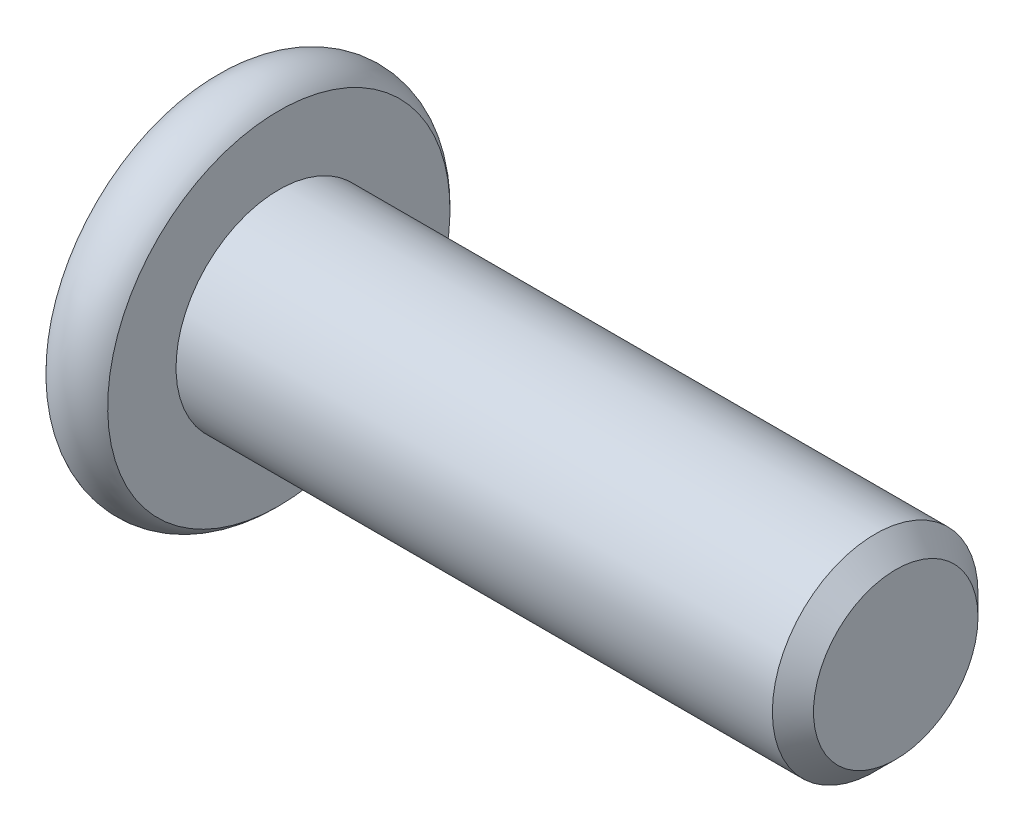
from build123d import *

# Parameters (mm, degrees)
SKETCH2_R           = 2.5
BOSS_EXTRUDE1_DEPTH = 15
CHAMFER1_SIZE       = 0.5
CUT_EXTRUDE1_DEPTH  = 2.3
SKETCH8_R           = 1.782050808
CUT_EXTRUDE2_DEPTH  = 1
CUT_EXTRUDE2_TAPER  = 45


with BuildPart() as part:
    # Sketch2 → Boss-Extrude1 (new body)
    with BuildSketch(Plane(origin=(0, 0, 0), x_dir=(0, 0, -1), z_dir=(1, 0, 0))):
        Circle(SKETCH2_R)
    extrude(amount=-BOSS_EXTRUDE1_DEPTH)

    # Chamfer1
    chamfer1_edges = [part.edges().sort_by_distance(p)[0] for p in [
        (0, 0, 2.5),
    ]]
    chamfer(chamfer1_edges, length=CHAMFER1_SIZE)

    # Sketch6 → Revolve1 (revolve)
    with BuildSketch(Plane.XY):
        with BuildLine():
            Line((-16.5, 0), (-16.5, 4.161437828))
            ThreePointArc((-16.5, 4.161437828), (-15.75, 4.5), (-15, 4.161437828))
            Line((-15, 4.161437828), (-15, 0))
            Line((-15, 0), (-16.5, 0))
        make_face()
    revolve(axis=Axis((-15, 0, 0), (1, 0, 0)))

    # Sketch7 → Cut-Extrude1 (cut)
    with BuildSketch(Plane.ZY.offset(16.5)):
        Polygon((0, 1.732050808), (-1.5, 0.866025404), (-1.5, -0.866025404), (0, -1.732050808), (1.5, -0.866025404), (1.5, 0.866025404), align=None)
    extrude(amount=-CUT_EXTRUDE1_DEPTH, mode=Mode.SUBTRACT)

    # Sketch8 → Cut-Extrude2 (cut)
    with BuildSketch(Plane.ZY.offset(16.5)):
        Circle(SKETCH8_R)
    extrude(amount=-CUT_EXTRUDE2_DEPTH, taper=CUT_EXTRUDE2_TAPER, mode=Mode.SUBTRACT)


solid = part.part
